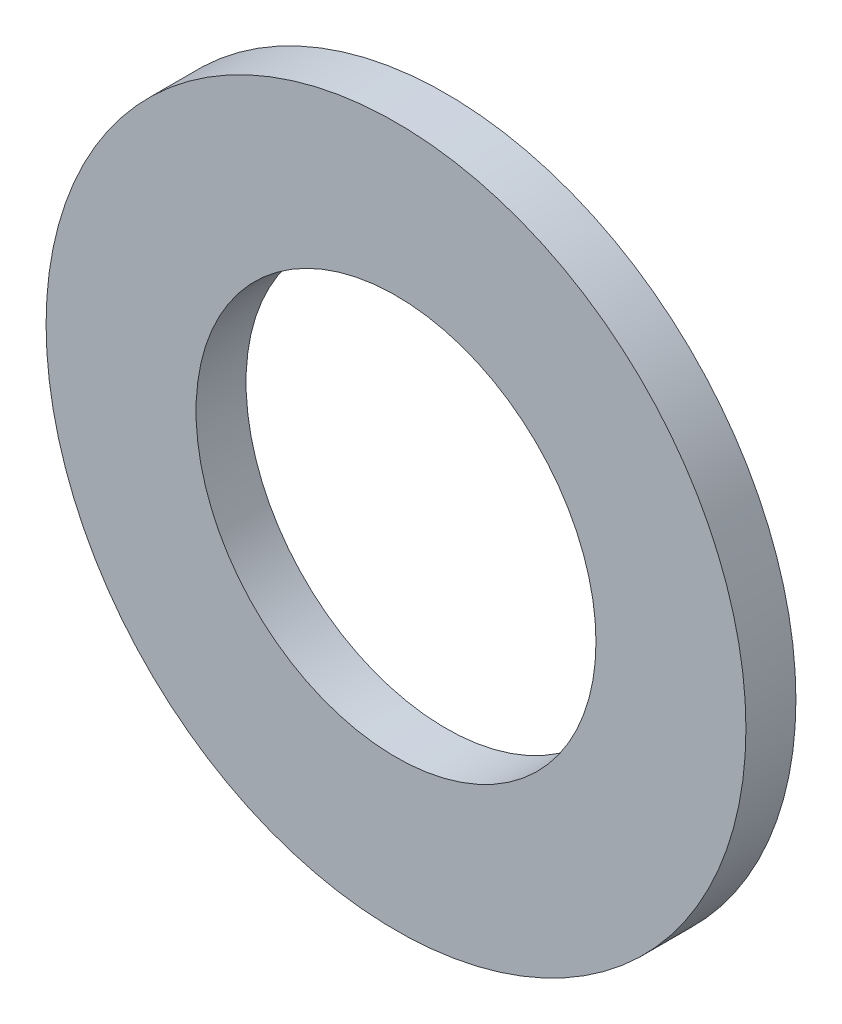
from build123d import *

# Parameters (mm, degrees)
SKETCH_1_R      = 3.5
SKETCH_1_R_2    = 2
EXTRUDE_1_DEPTH = 0.5


with BuildPart() as part:
    # 草图1 → 凸台-拉伸1 (new body)
    with BuildSketch(Plane.XY):
        Circle(SKETCH_1_R)
        Circle(SKETCH_1_R_2, mode=Mode.SUBTRACT)
    extrude(amount=EXTRUDE_1_DEPTH)


solid = part.part
